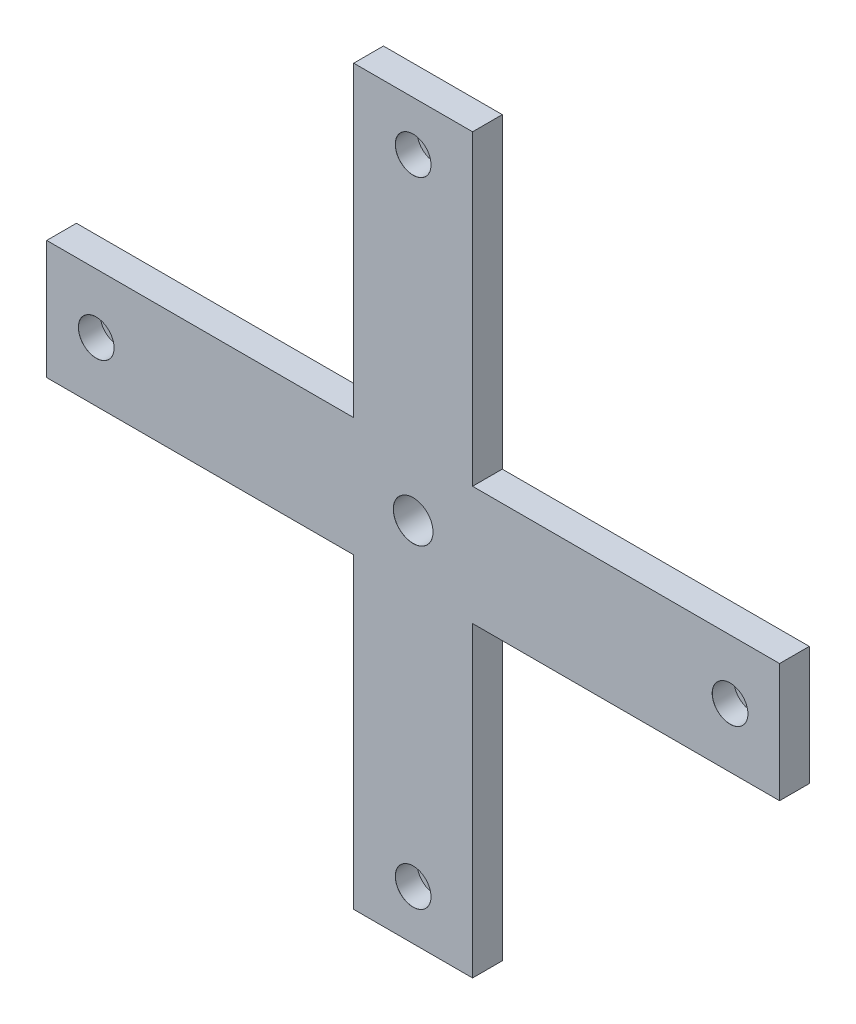
from build123d import *

# Parameters (mm, degrees)
SKETCH_1_W               = 370
SKETCH_1_H               = 370
EXTRUDE_1_DEPTH          = 15
SKETCH_2_W               = 155
SKETCH_2_H               = 155
CUT_EXTRUDE_1_DEPTH      = 20
HOLE_WIZARD_1_AT_2_COUNT = 2
HOLE_WIZARD_1_AT_2_PITCH = 320
HOLE_WIZARD_1_AT_3_COUNT = 2
HOLE_WIZARD_1_AT_3_PITCH = 226.27416998
HOLE_WIZARD_1_AT_4_COUNT = 2
HOLE_WIZARD_1_AT_4_PITCH = 226.27416998
MM_1_D                   = 20
MM_1_DEPTH               = 17
MM_1_CSINK_D             = 20.05
MM_1_CSINK_ANGLE         = 90
MM_1_TIP                 = 6.00860619


with BuildPart() as part:
    # 草图1 → 凸台-拉伸1 (new body)
    with BuildSketch(Plane.XY):
        Rectangle(SKETCH_1_W, SKETCH_1_H)
    extrude(amount=EXTRUDE_1_DEPTH)

    # 草图2 → 切除-拉伸1 (cut)
    with BuildSketch(Plane.XY.offset(15)):
        with Locations((107.5, 107.5)):
            Rectangle(SKETCH_2_W, SKETCH_2_H)
        with Locations((-107.5, 107.5)):
            Rectangle(SKETCH_2_W, SKETCH_2_H)
        with Locations((-107.5, -107.5)):
            Rectangle(SKETCH_2_W, SKETCH_2_H)
        with Locations((107.5, -107.5)):
            Rectangle(SKETCH_2_W, SKETCH_2_H)
    extrude(amount=-CUT_EXTRUDE_1_DEPTH, mode=Mode.SUBTRACT)

    # 草图4 → 打孔尺寸(%根据)内六角圆柱头螺钉的类型1 (revolve, cut)
    with BuildSketch(Plane(origin=(-160, 0, 15), x_dir=(0, -1, 0), z_dir=(1, 0, 0))):
        Polygon((0, 0), (0, 20.304733405), (5.5, 17), (5.5, 11), (9, 11), (9, 0.025), (9.025, 0), align=None)
    hole_wizard_1 = revolve(axis=Axis((-160, 0, 21.35), (0, 0, -1)), mode=Mode.SUBTRACT)

    # 打孔尺寸(%根据)内六角圆柱头螺钉的类型1 at 2: 打孔尺寸(%根据)内六角圆柱头螺钉的类型1 ×2
    with Locations(*[(i * HOLE_WIZARD_1_AT_2_PITCH, 0, 0) for i in range(1, HOLE_WIZARD_1_AT_2_COUNT)]):
        add(hole_wizard_1, mode=Mode.SUBTRACT)

    # 打孔尺寸(%根据)内六角圆柱头螺钉的类型1 at 3: 打孔尺寸(%根据)内六角圆柱头螺钉的类型1 ×2
    with Locations(*[Vector(0.707106781, 0.707106781, 0) * (i * HOLE_WIZARD_1_AT_3_PITCH) for i in range(1, HOLE_WIZARD_1_AT_3_COUNT)]):
        add(hole_wizard_1, mode=Mode.SUBTRACT)

    # 打孔尺寸(%根据)内六角圆柱头螺钉的类型1 at 4: 打孔尺寸(%根据)内六角圆柱头螺钉的类型1 ×2
    with Locations(*[Vector(0.707106781, -0.707106781, 0) * (i * HOLE_WIZARD_1_AT_4_PITCH) for i in range(1, HOLE_WIZARD_1_AT_4_COUNT)]):
        add(hole_wizard_1, mode=Mode.SUBTRACT)

    # 大小mm 暗销槽口1
    with Locations(Plane.XY.offset(15)):
        with Locations((0, 0)):
            CounterSinkHole(MM_1_D / 2, MM_1_CSINK_D / 2, depth=MM_1_DEPTH, counter_sink_angle=MM_1_CSINK_ANGLE)
            with Locations((0, 0, -(MM_1_DEPTH + MM_1_TIP / 2))):  # 118° drill point
                Cone(0, MM_1_D / 2, MM_1_TIP, mode=Mode.SUBTRACT)


solid = part.part
